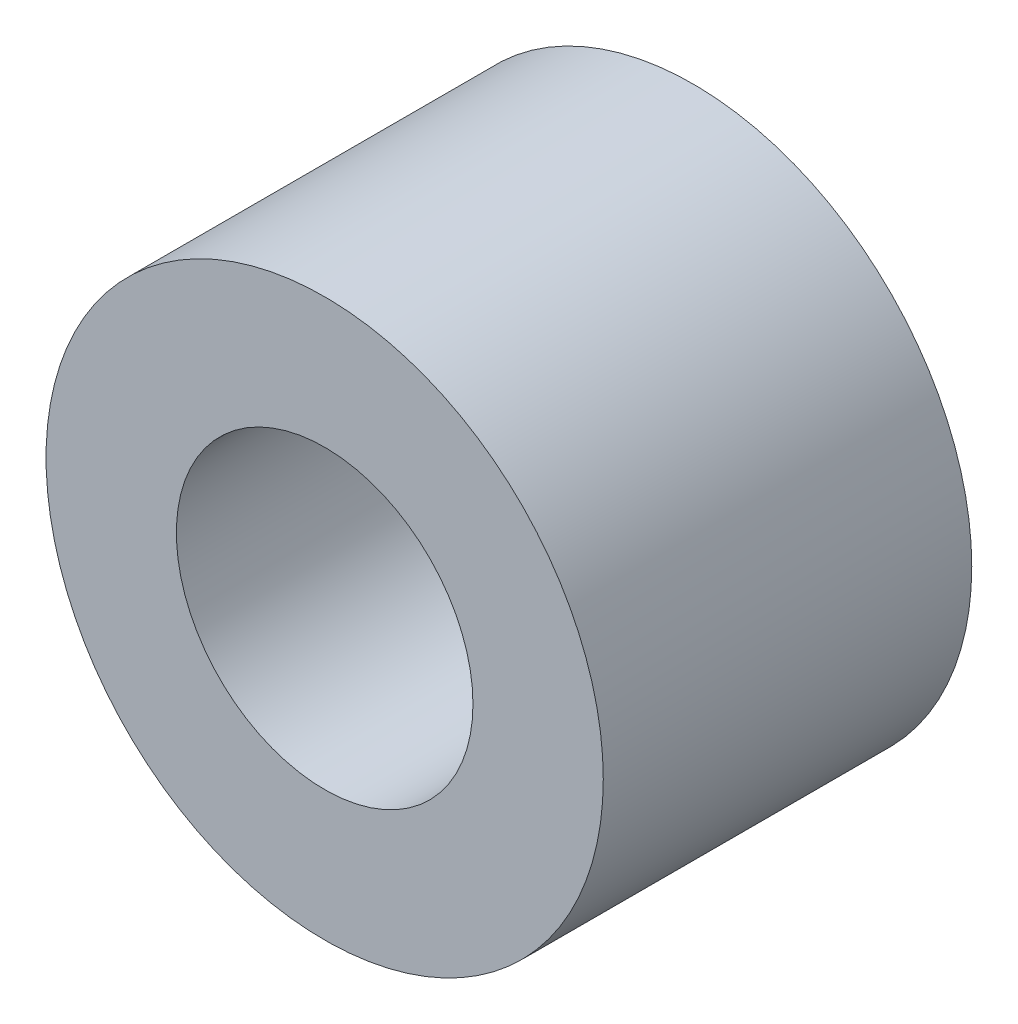
from build123d import *

# Parameters (mm, degrees)
SKETCH1_R           = 3.1
SKETCH1_R_2         = 1.65
BOSS_EXTRUDE1_DEPTH = 4.1


with BuildPart() as part:
    # Sketch1 → Boss-Extrude1 (new body)
    with BuildSketch(Plane.XY):
        Circle(SKETCH1_R)
        Circle(SKETCH1_R_2, mode=Mode.SUBTRACT)
    extrude(amount=BOSS_EXTRUDE1_DEPTH)


solid = part.part
